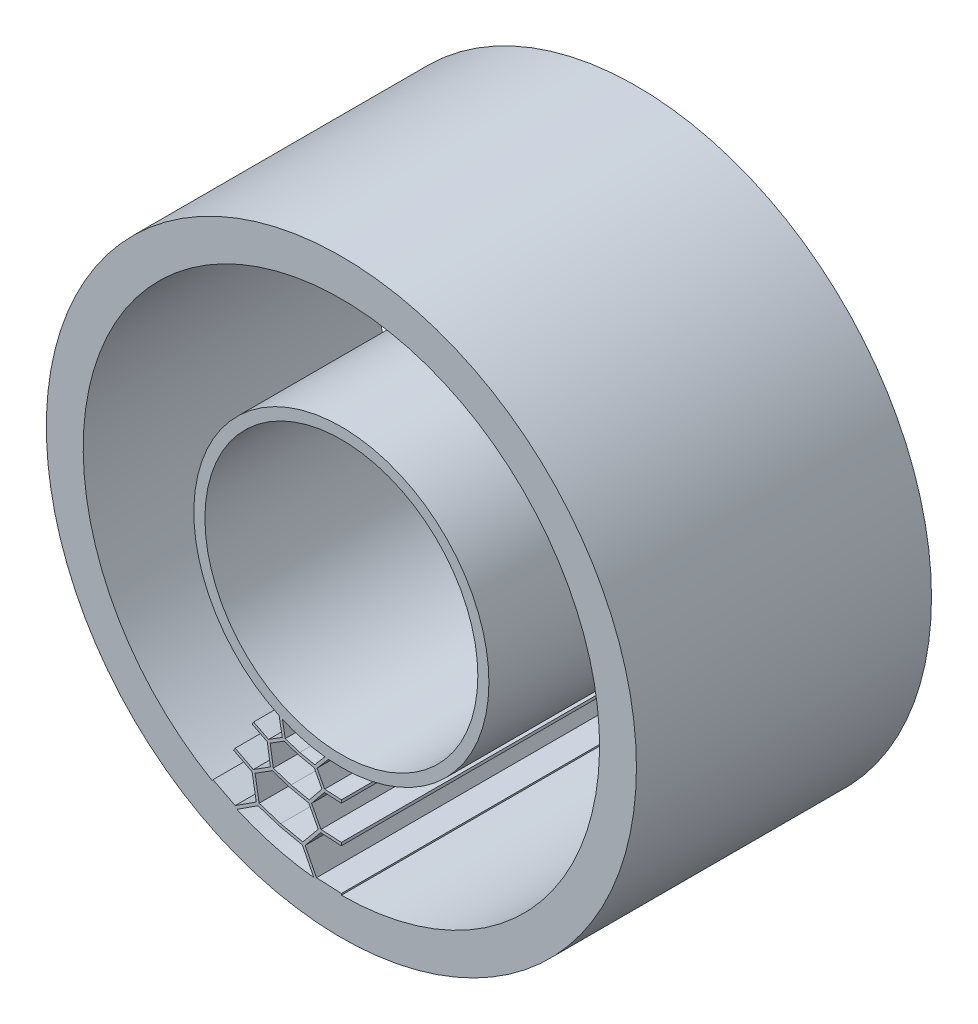
from build123d import *

# Parameters (mm, degrees)
BOSS_EXTRUDE1_DEPTH = 40
SKETCH1_6_R         = 40
SKETCH1_6_R_2       = 35
SKETCH1_6_R_3       = 20
SKETCH1_6_R_4       = 18.5
BOSS_EXTRUDE2_DEPTH = 40


with BuildPart() as part:
    # Sketch1 → Boss-Extrude1 (new body)
    with BuildSketch(Plane.XY):
        with BuildLine():
            Line((0, -29.2), (0, -29))
            Line((0, -29), (-2.896372732, -28.855))
            Line((-2.896372732, -28.855), (-5.153701873, -31.582263329))
            Line((-5.153701873, -31.582263329), (-3.495622262, -34.825))
            ThreePointArc((-3.495622262, -34.825), (-1.75, -34.956222622), (0, -35))
            Line((0, -35), (0, -34.8))
            Line((0, -34.8), (-3.370043386, -34.631286807))
            Line((-3.370043386, -34.631286807), (-4.915711127, -31.608396089))
            Line((-4.915711127, -31.608396089), (-2.806033523, -29.059522617))
            Line((-2.806033523, -29.059522617), (0, -29.2))
        make_face()
        with BuildLine():
            Line((-3.495622262, -34.825), (-5.153701873, -31.582263329))
            Line((-5.153701873, -31.582263329), (-8.282209443, -30.909626441))
            Line((-8.282209443, -30.909626441), (-8.334038079, -31.103053542))
            Line((-8.334038079, -31.103053542), (-5.288554278, -31.757840113))
            Line((-5.288554278, -31.757840113), (-3.732843691, -34.800371808))
            ThreePointArc((-3.732843691, -34.800371808), (-3.614253954, -34.812887963), (-3.495622262, -34.825))
        make_face()
        Polygon((-5.153701873, -31.582263329), (-2.896372732, -28.855), (-4.278593468, -26.219534795), (-6.875874487, -25.661112933), (-6.927703123, -25.854540034), (-4.412206949, -26.395377951), (-3.135314054, -28.830015709), (-5.230359841, -31.36121129), (-8.230380808, -30.716199341), (-8.282209443, -30.909626441), align=None)
        Polygon((-2.896372732, -28.855), (0, -29), (0, -28.8), (-2.772167607, -28.661218034), (-4.040561936, -26.2427844), (-2.303365501, -24.084687494), (0, -24.2), (0, -24), (-2.395409567, -23.880079527), (-4.278593468, -26.219534795), align=None)
        Polygon((-6.875874487, -25.661112933), (-4.278593468, -26.219534795), (-2.395409567, -23.880079527), (-3.543170038, -21.712806039), (-5.694018992, -21.250368178), (-5.745847628, -21.443795279), (-3.676306485, -21.888751758), (-2.633800725, -23.857276683), (-4.357083522, -25.998088853), (-6.824045852, -25.467685833), align=None)
        with BuildLine():
            Line((-3.543170038, -21.712806039), (-2.395409567, -23.880079527))
            Line((-2.395409567, -23.880079527), (0, -24))
            Line((0, -24), (0, -23.8))
            Line((0, -23.8), (-2.271732982, -23.686271101))
            Line((-2.271732982, -23.686271101), (-3.30286447, -21.73922379))
            Line((-3.30286447, -21.73922379), (-1.754210625, -19.922920094))
            ThreePointArc((-1.754210625, -19.922920094), (-1.875889536, -19.91183162), (-1.997498436, -19.9))
            Line((-1.997498436, -19.9), (-3.543170038, -21.712806039))
        make_face()
        with BuildLine():
            Line((-5.694018992, -21.250368178), (-3.543170038, -21.712806039))
            Line((-3.543170038, -21.712806039), (-1.997498436, -19.9))
            ThreePointArc((-1.997498436, -19.9), (-2.118012645, -19.887534348), (-2.238449128, -19.874338869))
            Line((-2.238449128, -19.874338869), (-3.617879715, -21.492172887))
            Line((-3.617879715, -21.492172887), (-5.642190357, -21.056941078))
            Line((-5.642190357, -21.056941078), (-5.694018992, -21.250368178))
        make_face()
    boss_extrude1 = extrude(amount=BOSS_EXTRUDE1_DEPTH)

    # Sketch1_6 → Boss-Extrude2 (add)
    with BuildSketch(Plane.XY):
        Circle(SKETCH1_6_R)
        Circle(SKETCH1_6_R_2, mode=Mode.SUBTRACT)
        Circle(SKETCH1_6_R_3)
        Circle(SKETCH1_6_R_4, mode=Mode.SUBTRACT)
    extrude(amount=BOSS_EXTRUDE2_DEPTH)

    # Mirror1: Boss-Extrude1 across plane
    add(boss_extrude1.mirror(Plane(origin=(0, 0, 40), x_dir=(0, 0, 1), z_dir=(0.9659258262890685, -0.2588190451025203, 0))))


solid = part.part
